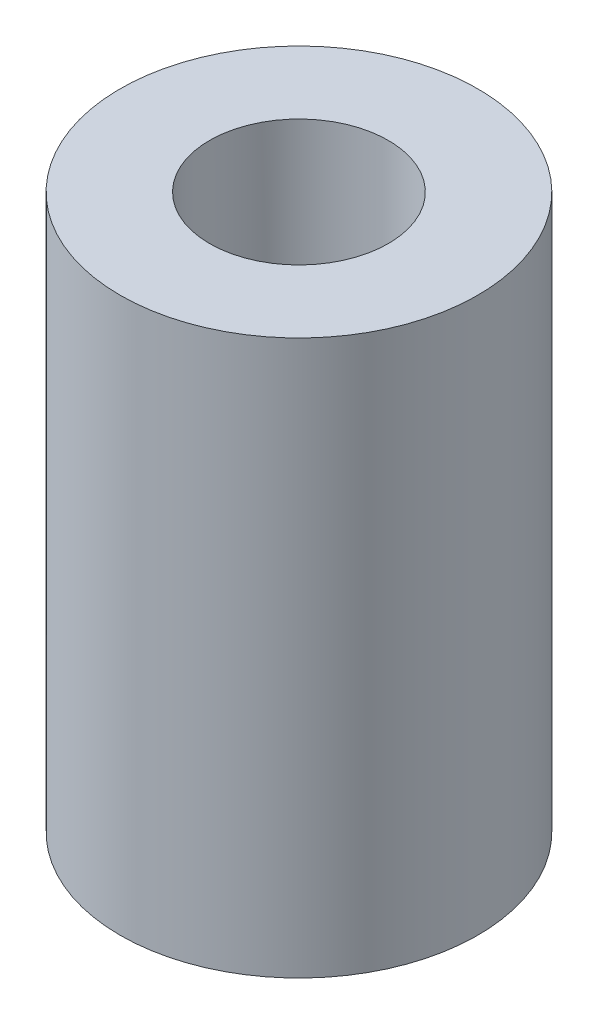
from build123d import *

# Parameters (mm, degrees)
SKETCH1_R           = 5
SKETCH1_R_2         = 2.5
BOSS_EXTRUDE1_DEPTH = 15.5
SKETCH2_R           = 1.5
CUT_EXTRUDE1_DEPTH  = 15.5


with BuildPart() as part:
    # Sketch1 → Boss-Extrude1 (new body)
    with BuildSketch(Plane(origin=(0, 0, 0), x_dir=(1, 0, 0), z_dir=(0, 1, 0))):
        Circle(SKETCH1_R)
        Circle(SKETCH1_R_2, mode=Mode.SUBTRACT)
    extrude(amount=BOSS_EXTRUDE1_DEPTH)

    # Sketch2 → Cut-Extrude1 (cut)
    with BuildSketch(Plane(origin=(0, 0, 0), x_dir=(0, 0, -1), z_dir=(1, 0, 0))):
        with Locations((0, 10.98)):
            Circle(SKETCH2_R)
    extrude(amount=-CUT_EXTRUDE1_DEPTH, mode=Mode.SUBTRACT)


solid = part.part
